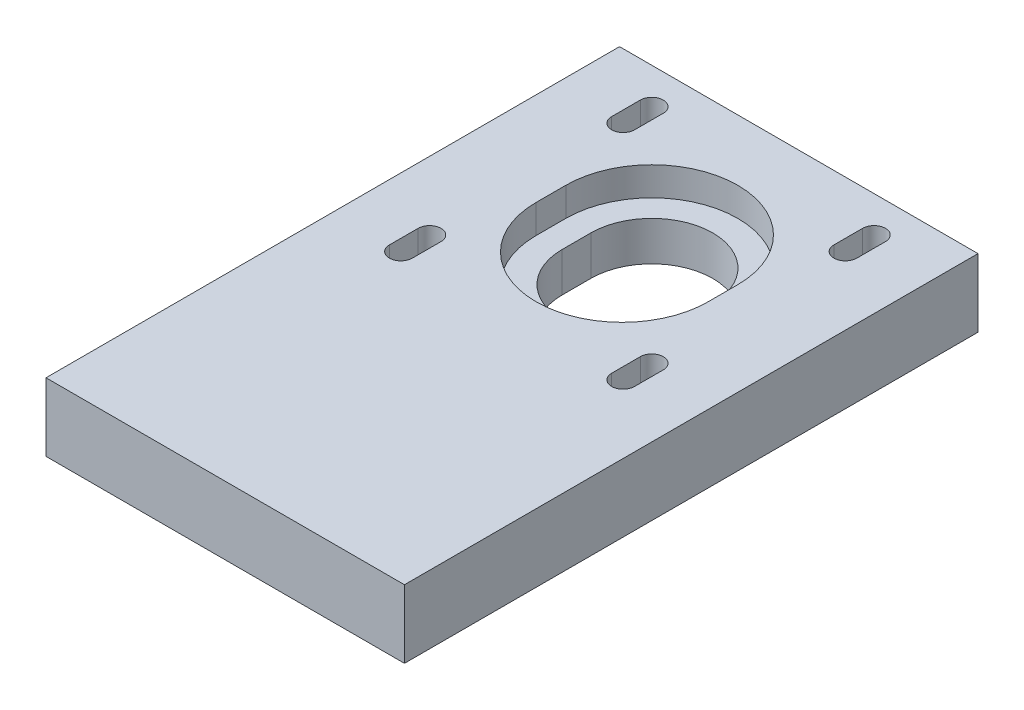
from build123d import *

# Parameters (mm, degrees)
SKETCH1_W           = 50
SKETCH1_H           = 80
BOSS_EXTRUDE1_DEPTH = 9.5
CUT_EXTRUDE1_DEPTH  = 10.5
CUT_EXTRUDE2_DEPTH  = 4


with BuildPart() as part:
    # Sketch1 → Boss-Extrude1 (new body)
    with BuildSketch(Plane(origin=(0, 0, 0), x_dir=(1, 0, 0), z_dir=(0, 1, 0))):
        Rectangle(SKETCH1_W, SKETCH1_H)
    extrude(amount=BOSS_EXTRUDE1_DEPTH)

    # Sketch2 → Cut-Extrude1 (cut, through all)
    with BuildSketch(Plane(origin=(0, 9.5, 0), x_dir=(1, 0, 0), z_dir=(0, 1, 0))):
        with BuildLine():
            Line((-13.9, 35), (-13.9, 31))
            ThreePointArc((-13.9, 31), (-15.5, 29.4), (-17.1, 31))
            Line((-17.1, 31), (-17.1, 35))
            ThreePointArc((-17.1, 35), (-15.5, 36.6), (-13.9, 35))
        make_face()
        with BuildLine():
            Line((13.9, 35), (13.9, 31))
            ThreePointArc((13.9, 31), (15.5, 29.4), (17.1, 31))
            Line((17.1, 31), (17.1, 35))
            ThreePointArc((17.1, 35), (15.5, 36.6), (13.9, 35))
        make_face()
        with BuildLine():
            Line((-13.9, 4), (-13.9, 0))
            ThreePointArc((-13.9, 0), (-15.5, -1.6), (-17.1, 0))
            Line((-17.1, 0), (-17.1, 4))
            ThreePointArc((-17.1, 4), (-15.5, 5.6), (-13.9, 4))
        make_face()
        with BuildLine():
            Line((13.9, 4), (13.9, 0))
            ThreePointArc((13.9, 0), (15.5, -1.6), (17.1, 0))
            Line((17.1, 0), (17.1, 4))
            ThreePointArc((17.1, 4), (15.5, 5.6), (13.9, 4))
        make_face()
        with BuildLine():
            Line((8.5, 19.5), (8.5, 15.5))
            ThreePointArc((8.5, 15.5), (0, 7), (-8.5, 15.5))
            Line((-8.5, 15.5), (-8.5, 19.5))
            ThreePointArc((-8.5, 19.5), (0, 28), (8.5, 19.5))
        make_face()
    extrude(amount=-CUT_EXTRUDE1_DEPTH, mode=Mode.SUBTRACT)

    # Sketch3 → Cut-Extrude2 (cut)
    with BuildSketch(Plane(origin=(0, 9.5, 0), x_dir=(1, 0, 0), z_dir=(0, 1, 0))):
        with BuildLine():
            Line((12, 19.5), (12, 15.358826141))
            ThreePointArc((12, 15.358826141), (0, 3.358826141), (-12, 15.358826141))
            Line((-12, 15.358826141), (-12, 19.5))
            ThreePointArc((-12, 19.5), (0, 31.5), (12, 19.5))
        make_face()
    extrude(amount=-CUT_EXTRUDE2_DEPTH, mode=Mode.SUBTRACT)


solid = part.part
